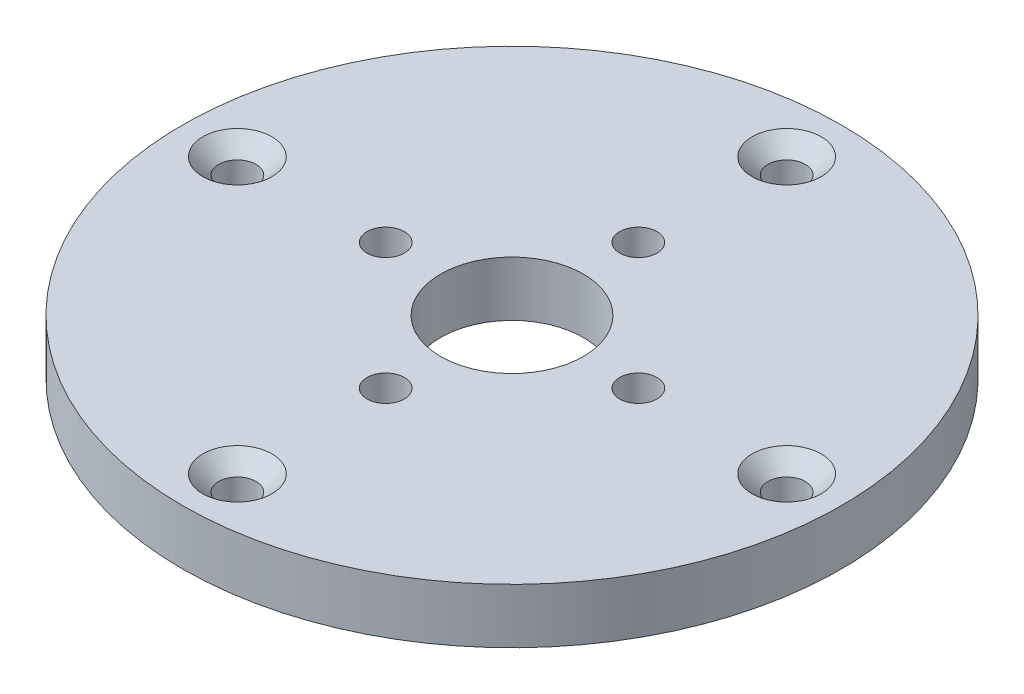
from build123d import *

# Parameters (mm, degrees)
SKETCH1_R                                           = 30
SKETCH1_R_2                                         = 6.5
BOSS_EXTRUDE1_DEPTH                                 = 5
CSK_FOR_M3_COUNTERSUNK_FLAT_HEAD_SCREW1_D           = 3.4
CSK_FOR_M3_COUNTERSUNK_FLAT_HEAD_SCREW1_DEPTH       = 5
CSK_FOR_M3_COUNTERSUNK_FLAT_HEAD_SCREW1_CSINK_D     = 6.3
CSK_FOR_M3_COUNTERSUNK_FLAT_HEAD_SCREW1_CSINK_ANGLE = 90
CSK_FOR_M3_COUNTERSUNK_FLAT_HEAD_SCREW2_D           = 3.4
CSK_FOR_M3_COUNTERSUNK_FLAT_HEAD_SCREW2_DEPTH       = 5
CSK_FOR_M3_COUNTERSUNK_FLAT_HEAD_SCREW2_CSINK_D     = 6.3
CSK_FOR_M3_COUNTERSUNK_FLAT_HEAD_SCREW2_CSINK_ANGLE = 90


with BuildPart() as part:
    # Sketch1 → Boss-Extrude1 (new body)
    with BuildSketch(Plane(origin=(0, 0, 0), x_dir=(1, 0, 0), z_dir=(0, 1, 0))):
        Circle(SKETCH1_R)
        Circle(SKETCH1_R_2, mode=Mode.SUBTRACT)
    extrude(amount=BOSS_EXTRUDE1_DEPTH)

    # CSK for M3 Countersunk Flat Head Screw1
    with Locations(Plane(origin=(0, 5, 0), x_dir=(1, 0, 0), z_dir=(0, 1, 0))):
        with Locations((0, 25), (-25, 0), (0, -25), (25, 0)):
            CounterSinkHole(CSK_FOR_M3_COUNTERSUNK_FLAT_HEAD_SCREW1_D / 2, CSK_FOR_M3_COUNTERSUNK_FLAT_HEAD_SCREW1_CSINK_D / 2, depth=CSK_FOR_M3_COUNTERSUNK_FLAT_HEAD_SCREW1_DEPTH, counter_sink_angle=CSK_FOR_M3_COUNTERSUNK_FLAT_HEAD_SCREW1_CSINK_ANGLE)

    # CSK for M3 Countersunk Flat Head Screw2
    with Locations(Plane(origin=(0, 0, 0), x_dir=(-1, 0, 0), z_dir=(0, -1, 0))):
        with Locations((0, 11.5), (-11.5, 0), (0, -11.5), (11.5, 0)):
            CounterSinkHole(CSK_FOR_M3_COUNTERSUNK_FLAT_HEAD_SCREW2_D / 2, CSK_FOR_M3_COUNTERSUNK_FLAT_HEAD_SCREW2_CSINK_D / 2, depth=CSK_FOR_M3_COUNTERSUNK_FLAT_HEAD_SCREW2_DEPTH, counter_sink_angle=CSK_FOR_M3_COUNTERSUNK_FLAT_HEAD_SCREW2_CSINK_ANGLE)


solid = part.part
